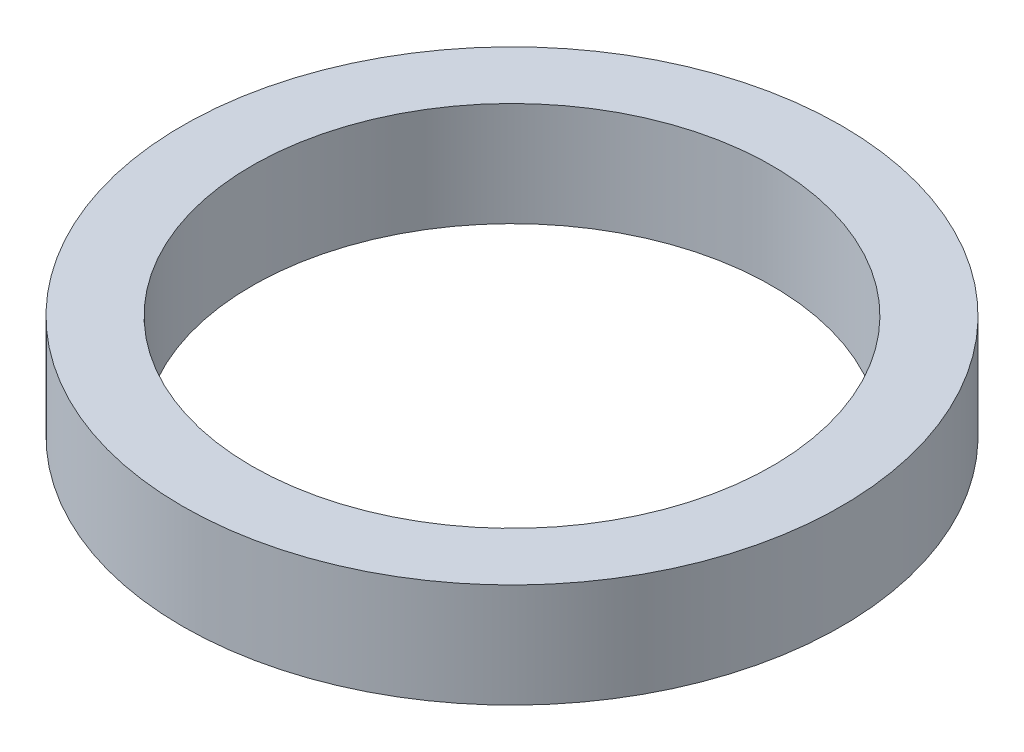
from build123d import *

# Parameters (mm, degrees)
ESQUISSE1_R        = 19
ESQUISSE1_R_2      = 15
BOSS_EXTRU_1_DEPTH = 6


with BuildPart() as part:
    # Esquisse1 → Boss.-Extru.1 (new body)
    with BuildSketch(Plane(origin=(0, 0, 0), x_dir=(1, 0, 0), z_dir=(0, 1, 0))):
        with Locations(Location((0, 0, 0), (0, 0, 270))):  # turned: the seam where the file's is
            Circle(ESQUISSE1_R)
        with Locations(Location((0, 0, 0), (0, 0, 270))):  # turned: the seam where the file's is
            Circle(ESQUISSE1_R_2, mode=Mode.SUBTRACT)
    extrude(amount=BOSS_EXTRU_1_DEPTH)


solid = part.part
